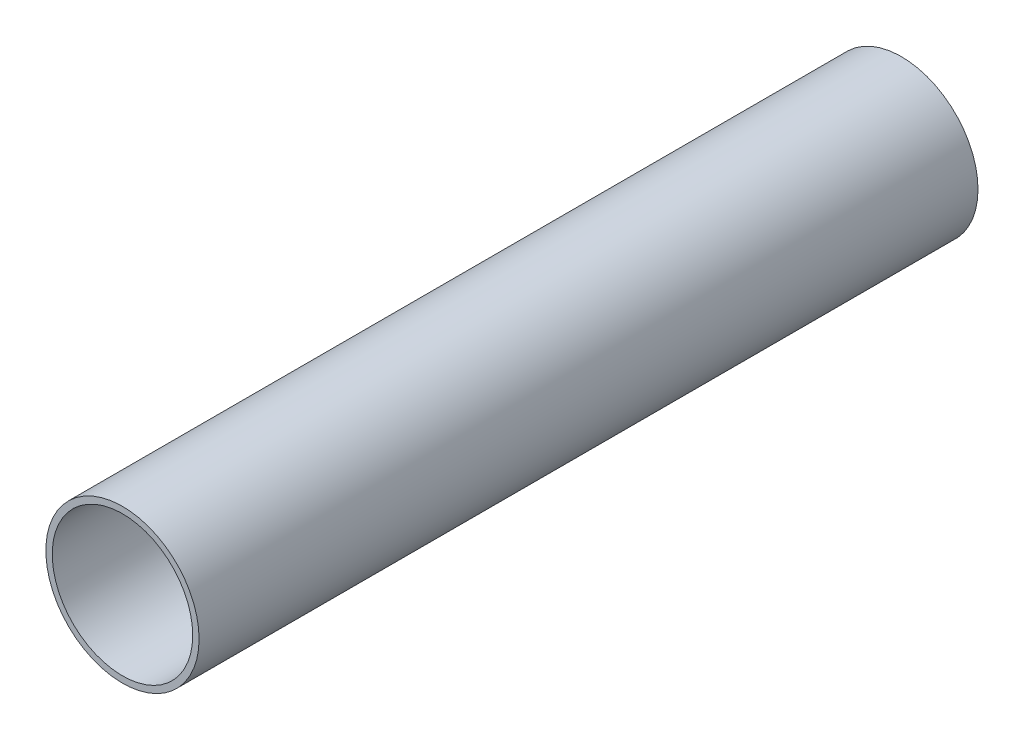
from build123d import *

# Parameters (mm, degrees)
SKETCH1_R           = 76.2
SKETCH1_R_2         = 69.85
BOSS_EXTRUDE1_DEPTH = 762
BOSS_EXTRUDE2_START = -12.7
SKETCH1_3_R         = 76.2
SKETCH1_3_R_2       = 63.5
BOSS_EXTRUDE2_DEPTH = 12.7


with BuildPart() as part:
    # Sketch1 → Boss-Extrude1 (new body)
    with BuildSketch(Plane.XY):
        Circle(SKETCH1_R)
        Circle(SKETCH1_R_2, mode=Mode.SUBTRACT)
    extrude(amount=BOSS_EXTRUDE1_DEPTH)

    # Sketch1_3 → Boss-Extrude2 (add)
    with BuildSketch(Plane.XY.offset(BOSS_EXTRUDE2_START)):
        Circle(SKETCH1_3_R)
        Circle(SKETCH1_3_R_2, mode=Mode.SUBTRACT)
    extrude(amount=BOSS_EXTRUDE2_DEPTH)


solid = part.part
